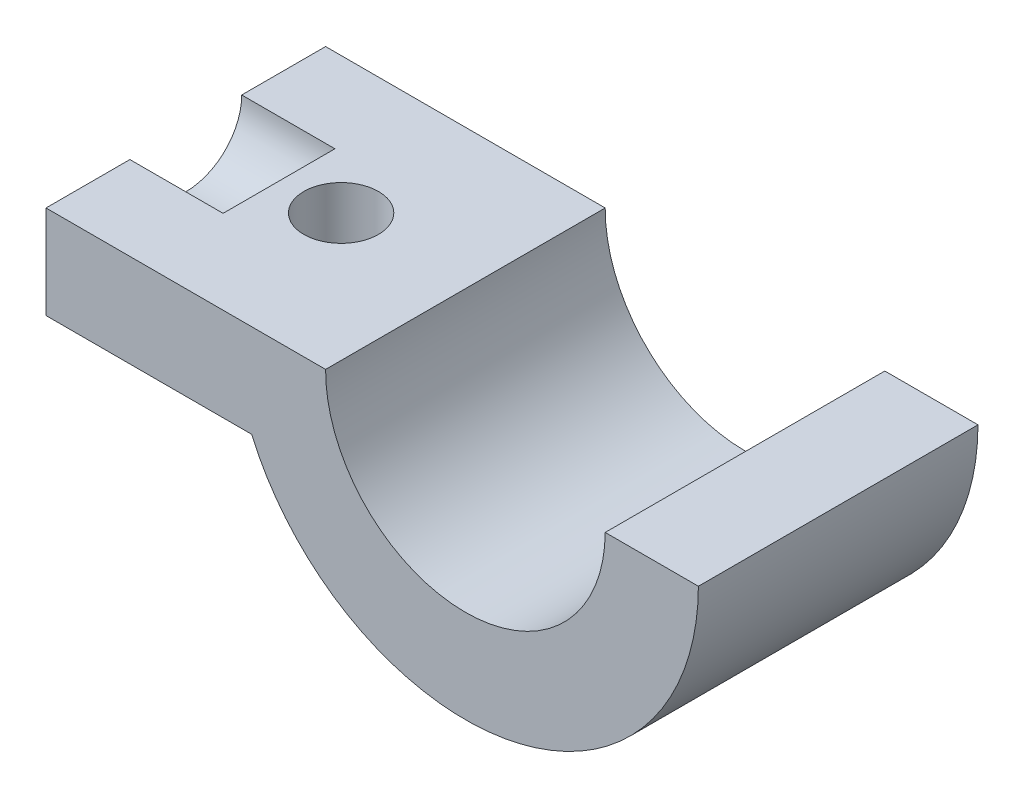
from build123d import *

# Parameters (mm, degrees)
EXTRUDE_1_DEPTH     = 1.5
SKETCH_3_R          = 0.3
CUT_EXTRUDE_1_DEPTH = 0.5
SKETCH_4_R          = 0.2
CUT_EXTRUDE_2_DEPTH = 0.5


with BuildPart() as part:
    # 草图2 → 凸台-拉伸1 (new body)
    with BuildSketch(Plane.XY):
        with BuildLine():
            Line((9.249993009, -2.386934839), (7.749993009, -2.386934839))
            Line((7.749993009, -2.386934839), (7.749993009, -2.886934839))
            Line((7.749993009, -2.886934839), (8.853123955, -2.886934839))
            ThreePointArc((8.853123955, -2.886934839), (10.251588952, -3.614156243), (11.249979027, -2.394413411))
            Line((11.249979027, -2.394413411), (10.749979027, -2.394413411))
            ThreePointArc((10.749979027, -2.394413411), (9.996246732, -3.140667133), (9.249993009, -2.386934839))
        make_face()
    extrude(amount=-EXTRUDE_1_DEPTH)

    # 草图3 → 切除-拉伸1 (cut)
    with BuildSketch(Plane.ZY.offset(-7.749993009)):
        with Locations((-0.75, -2.386934839)):
            Circle(SKETCH_3_R)
    extrude(amount=-CUT_EXTRUDE_1_DEPTH, mode=Mode.SUBTRACT)

    # 草图4 → 切除-拉伸2 (cut)
    with BuildSketch(Plane(origin=(0, -2.386934839, 0), x_dir=(1, 0, 0), z_dir=(0, 1, 0))):
        with Locations((8.564809318, 0.768458185)):
            Circle(SKETCH_4_R)
    extrude(amount=-CUT_EXTRUDE_2_DEPTH, mode=Mode.SUBTRACT)


solid = part.part
